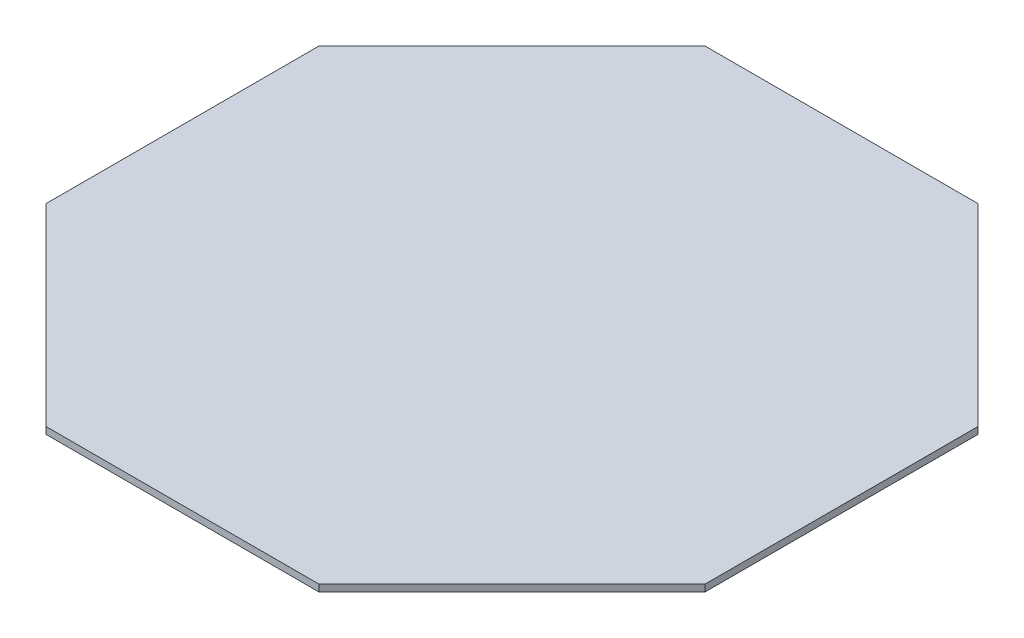
from build123d import *

# Parameters (mm, degrees)
EXTRUSION1_DEPTH = 3


with BuildPart() as part:
    # Esquisse1 → Extrusion1 (new body)
    with BuildSketch(Plane(origin=(0, 0, 0), x_dir=(1, 0, 0), z_dir=(0, 1, 0))):
        Polygon((144.852813742, 60), (60, 144.852813742), (-60, 144.852813742), (-144.852813742, 60), (-144.852813742, -60), (-60, -144.852813742), (60, -144.852813742), (144.852813742, -60), align=None)
    extrude(amount=EXTRUSION1_DEPTH)


solid = part.part
